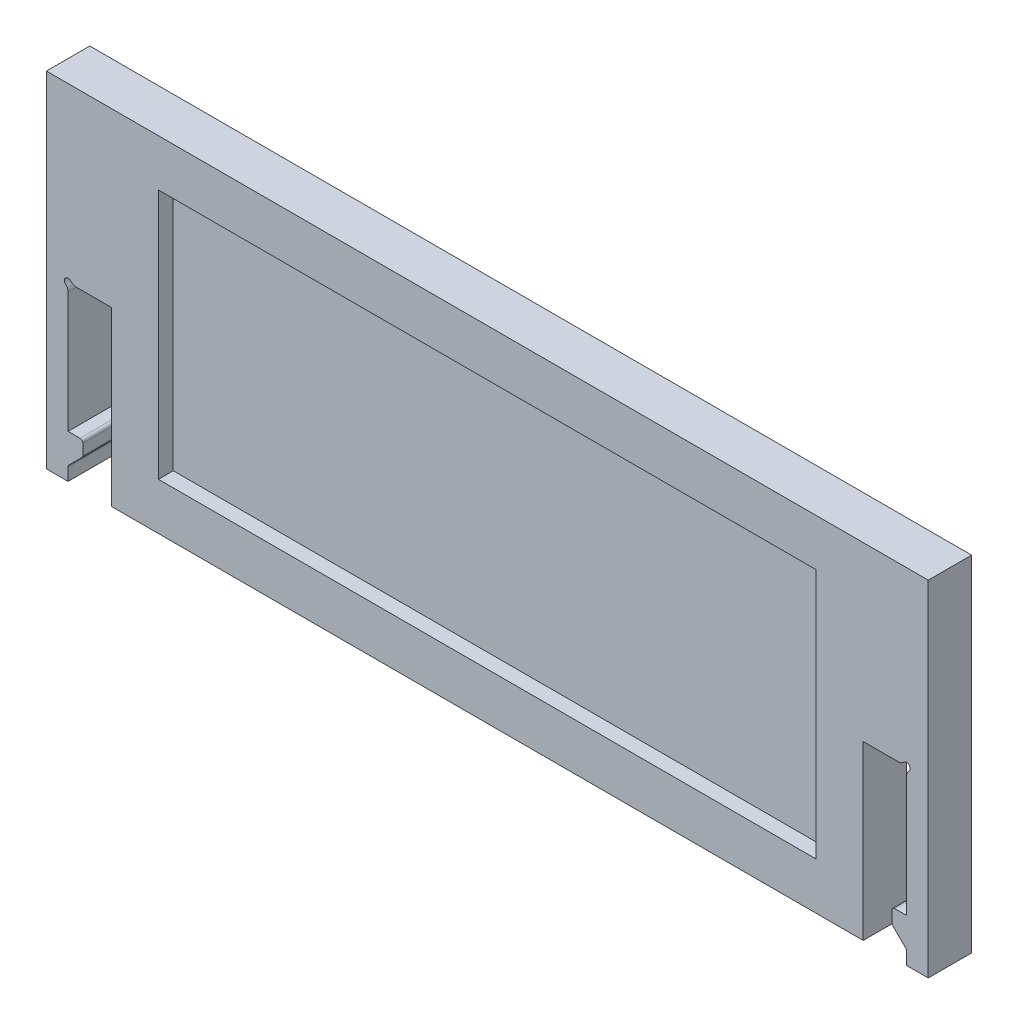
from build123d import *

# Parameters (mm, degrees)
SKETCH1_W            = 59.589999946
SKETCH1_H            = 23.283333334
BOSS_EXTRUDE1_DEPTH  = 2.929999982
SKETCH2_W            = 2.929999982
SKETCH2_H            = 11.641666667
CUT_EXTRUDE1_DEPTH   = 3.929999982
BOSS_EXTRUDE3_DEPTH  = 2.93
FILLET1_R            = 0.2
SKETCH5_R            = 0.25
CUT_EXTRUDE3_DEPTH   = 3.93
FILLET2_R            = 0.5
FILLET1_OF_MIRROR1_R = 0.2
FILLET2_OF_MIRROR1_R = 0.5
SKETCH3_W            = 44.45
SKETCH3_H            = 16.933333334
CUT_EXTRUDE2_DEPTH   = 1


with BuildPart() as part:
    # Sketch1 → Boss-Extrude1 (new body)
    with BuildSketch(Plane.XY):
        Rectangle(SKETCH1_W, SKETCH1_H)
    extrude(amount=BOSS_EXTRUDE1_DEPTH)

    # Sketch2 → Cut-Extrude1 (cut, through all)
    with BuildSketch(Plane.XY.offset(2.929999982)):
        with Locations((-26.864999991, -5.820833334)):
            Rectangle(SKETCH2_W, SKETCH2_H)
    cut_extrude1 = extrude(amount=-CUT_EXTRUDE1_DEPTH, mode=Mode.SUBTRACT)

    # Sketch4 → Boss-Extrude3 (add)
    with BuildSketch(Plane.XY.offset(2.929999982)):
        Polygon((-27.329999982, -8.711666685), (-28.329999982, -8.711666685), (-28.329999982, -10.711666685), (-27.329999982, -9.711666685), align=None)
    boss_extrude3 = extrude(amount=-BOSS_EXTRUDE3_DEPTH)

    # Fillet1
    fillet1_edges = [part.edges().sort_by_distance(p)[0] for p in [
        (-27.329999982, -8.711666685, 1.464999982),
        (-28.329999982, -10.711666685, 1.464999982),
        (-27.329999982, -9.711666685, 1.464999982),
    ]]
    fillet(fillet1_edges, radius=FILLET1_R)

    # Sketch5 → Cut-Extrude3 (cut, through all)
    with BuildSketch(Plane.XY.offset(2.929999982)):
        with Locations((-28.329999982, 0)):
            Circle(SKETCH5_R)
    cut_extrude3 = extrude(amount=-CUT_EXTRUDE3_DEPTH, mode=Mode.SUBTRACT)

    # Fillet2
    fillet2_edges = [part.edges().sort_by_distance(p)[0] for p in [
        (-28.079999982, 0, 1.464999991),
        (-28.329999982, -0.25, 1.464999991),
    ]]
    fillet(fillet2_edges, radius=FILLET2_R)

    # Mirror1: Cut-Extrude1, Boss-Extrude3, Cut-Extrude3 across plane
    add(cut_extrude1.mirror(Plane(origin=(0, 0, 0), x_dir=(0, 0, 1), z_dir=(1, 0, 0))), mode=Mode.SUBTRACT)
    add(boss_extrude3.mirror(Plane(origin=(0, 0, 0), x_dir=(0, 0, 1), z_dir=(1, 0, 0))))
    add(cut_extrude3.mirror(Plane(origin=(0, 0, 0), x_dir=(0, 0, 1), z_dir=(1, 0, 0))), mode=Mode.SUBTRACT)

    # Fillet1 of Mirror1
    fillet1_of_mirror1_edges = [part.edges().sort_by_distance(p)[0] for p in [
        (27.329999982, -8.711666685, 1.464999982),
        (28.329999982, -10.711666685, 1.464999982),
        (27.329999982, -9.711666685, 1.464999982),
    ]]
    fillet(fillet1_of_mirror1_edges, radius=FILLET1_OF_MIRROR1_R)

    # Fillet2 of Mirror1
    fillet2_of_mirror1_edges = [part.edges().sort_by_distance(p)[0] for p in [
        (28.079999982, 0, 1.464999991),
        (28.329999982, -0.25, 1.464999991),
    ]]
    fillet(fillet2_of_mirror1_edges, radius=FILLET2_OF_MIRROR1_R)

    # Sketch3 → Cut-Extrude2 (cut)
    with BuildSketch(Plane.XY.offset(2.929999982)):
        Rectangle(SKETCH3_W, SKETCH3_H)
    extrude(amount=-CUT_EXTRUDE2_DEPTH, mode=Mode.SUBTRACT)


solid = part.part
